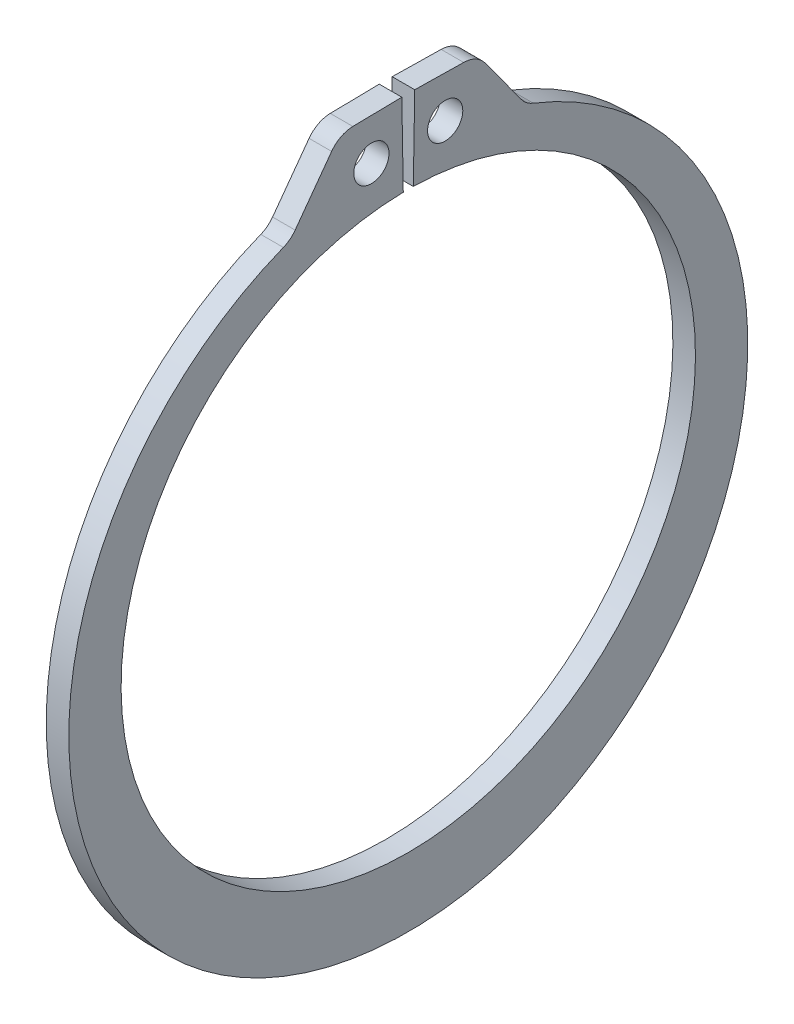
from build123d import *

# Parameters (mm, degrees)
SKETCH1_R      = 0.9906
EXTRUDE1_DEPTH = 0.635
FILLET1_R      = 1.5113


with BuildPart() as part:
    # Sketch1 → Extrude1 (new body, symmetric)
    with BuildSketch(Plane(origin=(0, 0, 0), x_dir=(0, 0, -1), z_dir=(1, 0, 0))):
        with BuildLine():
            Line((-0.281933155, 16.151939607), (-0.363498721, 20.824827795))
            Line((-0.363498721, 20.824827795), (-3.868164862, 20.76365362))
            Line((-3.868164862, 20.76365362), (-6.626403534, 16.99076926))
            ThreePointArc((-6.626403534, 16.99076926), (0, -20.0152), (6.626403534, 16.99076926))
            Line((6.626403534, 16.99076926), (3.868164862, 20.76365362))
            Line((3.868164862, 20.76365362), (0.363498721, 20.824827795))
            Line((0.363498721, 20.824827795), (0.281933155, 16.151939607))
            ThreePointArc((0.281933155, 16.151939607), (0, -16.1544), (-0.281933155, 16.151939607))
        make_face()
        with Locations((-2.075049008, 18.457796613)):
            Circle(SKETCH1_R, mode=Mode.SUBTRACT)
        with Locations((2.075049008, 18.457796613)):
            Circle(SKETCH1_R, mode=Mode.SUBTRACT)
    extrude(amount=EXTRUDE1_DEPTH, both=True)

    # Fillet1
    fillet1_edges = [part.edges().sort_by_distance(p)[0] for p in [
        (0, 20.76365362, -3.868164862),
        (0, 16.99076926, -6.626403534),
        (0, 16.99076926, 6.626403534),
        (0, 20.76365362, 3.868164862),
    ]]
    fillet(fillet1_edges, radius=FILLET1_R)


solid = part.part
